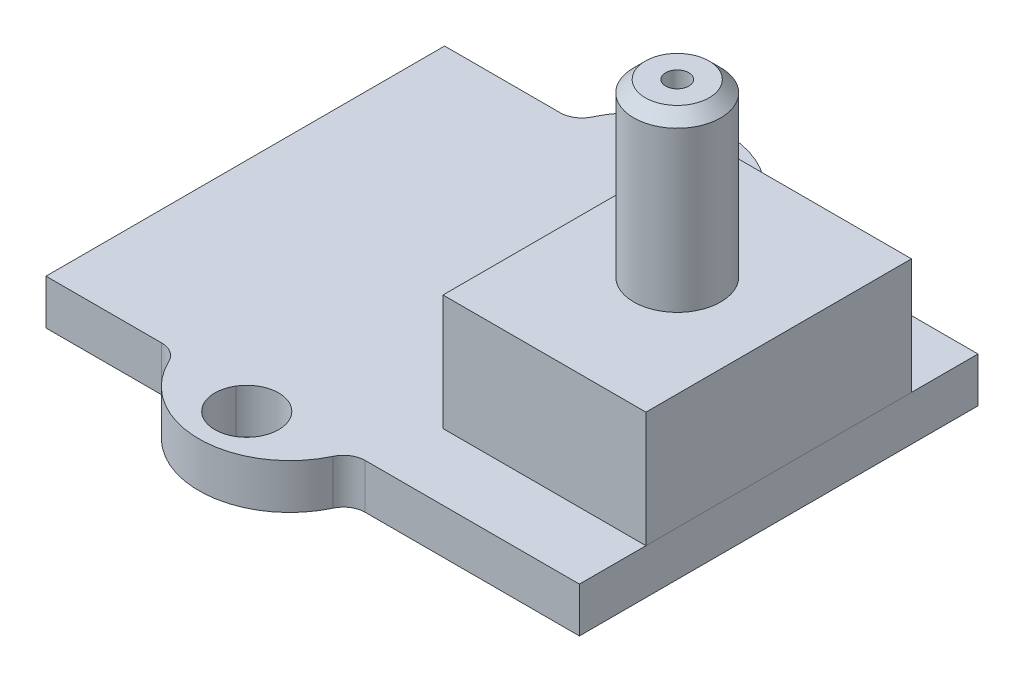
from build123d import *

# Parameters (mm, degrees)
SKETCH1_R           = 1.1
BOSS_EXTRUDE1_DEPTH = 1.55
BOSS_EXTRUDE2_START = 1.55
SKETCH1_3_W         = 7
SKETCH1_3_H         = 9.16
SKETCH1_3_R         = 1.5
SKETCH1_3_R_2       = 0.4
BOSS_EXTRUDE2_DEPTH = 3.99
BOSS_EXTRUDE3_START = 5.54
SKETCH1_4_R         = 1.5
SKETCH1_4_R_2       = 0.4
BOSS_EXTRUDE3_DEPTH = 5.9
CHAMFER1_SIZE       = 0.4
FILLET1_R           = 0.75


with BuildPart() as part:
    # Sketch1 → Boss-Extrude1 (new body)
    with BuildSketch(Plane(origin=(0, 0, 0), x_dir=(1, 0, 0), z_dir=(0, 1, 0))):
        with BuildLine():
            Line((-9.2, 6.875), (-9.2, -6.875))
            Line((-9.2, -6.875), (-4.7, -6.875))
            ThreePointArc((-4.7, -6.875), (-1.7, -9.1), (1.3, -6.875))
            Line((1.3, -6.875), (9.2, -6.875))
            Line((9.2, -6.875), (9.2, 6.875))
            Line((9.2, 6.875), (1.3, 6.875))
            ThreePointArc((1.3, 6.875), (-1.7, 9.1), (-4.7, 6.875))
            Line((-4.7, 6.875), (-9.2, 6.875))
        make_face()
        with Locations((-1.7, 7.45)):
            Circle(SKETCH1_R, mode=Mode.SUBTRACT)
        with Locations((-1.7, -7.45)):
            Circle(SKETCH1_R, mode=Mode.SUBTRACT)
    extrude(amount=BOSS_EXTRUDE1_DEPTH)

    # Fillet1
    fillet1_edges = [part.edges().sort_by_distance(p)[0] for p in [
        (-4.7, 0.775, 6.875),
        (-4.7, 0.775, -6.875),
        (1.3, 0.775, -6.875),
        (1.3, 0.775, 6.875),
    ]]
    fillet(fillet1_edges, radius=FILLET1_R)


with BuildPart() as body_2:
    # Sketch1_3 → Boss-Extrude2 (new body)
    with BuildSketch(Plane(origin=(0, 0, 0), x_dir=(1, 0, 0), z_dir=(0, 1, 0)).offset(BOSS_EXTRUDE2_START)):
        with Locations((5.7, 0)):
            Rectangle(SKETCH1_3_W, SKETCH1_3_H)
        with Locations((5.7, 0)):
            Circle(SKETCH1_3_R, mode=Mode.SUBTRACT)
        with Locations((5.7, 0)):
            Circle(SKETCH1_3_R)
        with Locations((5.7, 0)):
            Circle(SKETCH1_3_R_2, mode=Mode.SUBTRACT)
        with Locations((5.7, 0)):
            Circle(SKETCH1_3_R_2)
    extrude(amount=BOSS_EXTRUDE2_DEPTH)

    # Sketch1_4 → Boss-Extrude3 (add)
    with BuildSketch(Plane(origin=(0, 0, 0), x_dir=(1, 0, 0), z_dir=(0, 1, 0)).offset(BOSS_EXTRUDE3_START)):
        with Locations((5.7, 0)):
            Circle(SKETCH1_4_R)
        with Locations((5.7, 0)):
            Circle(SKETCH1_4_R_2, mode=Mode.SUBTRACT)
    extrude(amount=BOSS_EXTRUDE3_DEPTH)

    # Chamfer1
    chamfer1_edges = [body_2.edges().sort_by_distance(p)[0] for p in [
        (4.2, 11.44, 0),
    ]]
    chamfer(chamfer1_edges, length=CHAMFER1_SIZE)


solid = Compound([part.part, body_2.part])
